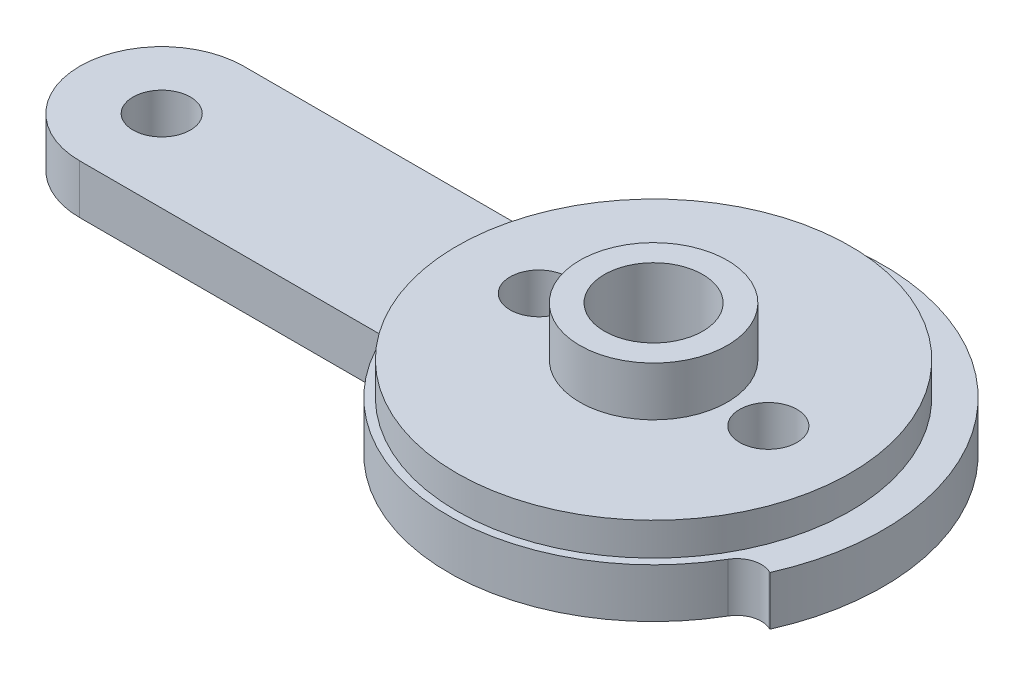
from build123d import *

# Parameters (mm, degrees)
SKETCH_1_R          = 1.75
EXTRUDE_1_DEPTH     = 3
SKETCH_2_R          = 12
EXTRUDE_2_DEPTH     = 2
SKETCH_3_R          = 4.5
SKETCH_3_R_2        = 3
EXTRUDE_3_DEPTH     = 3
SKETCH_4_R          = 3
CUT_EXTRUDE_1_DEPTH = 2
SKETCH_5_R          = 1.75
CUT_EXTRUDE_2_DEPTH = 9


with BuildPart() as part:
    # Эскиз1 → Бобышка-Вытянуть1 (new body)
    with BuildSketch(Plane(origin=(0, 0, 0), x_dir=(1, 0, 0), z_dir=(0, 1, 0))):
        with BuildLine():
            Line((-30, 5), (-11.456439237, 5))
            ThreePointArc((-11.456439237, 5), (-10.2750901, 7.118463559), (-8.706840344, 8.968886844))
            ThreePointArc((-8.706840344, 8.968886844), (-8.255178852, 9.942485712), (-8.569645055, 10.968645479))
            Line((-8.569645055, 10.968645479), (-8.619260655, 11.03215055))
            ThreePointArc((-8.619260655, 11.03215055), (8.619260655, 11.03215055), (12.789636407, -5.694313003))
            Line((12.789636407, -5.694313003), (12.716014607, -5.661534466))
            ThreePointArc((12.716014607, -5.661534466), (11.644259912, -5.604659769), (10.808847895, -6.278439868))
            ThreePointArc((10.808847895, -6.278439868), (-0.716551297, -12.47944527), (-11.456439237, -5))
            Line((-11.456439237, -5), (-30, -5))
            ThreePointArc((-30, -5), (-35, 0), (-30, 5))
        make_face()
        with Locations((-30, 0)):
            Circle(SKETCH_1_R, mode=Mode.SUBTRACT)
    extrude(amount=EXTRUDE_1_DEPTH)

    # Эскиз2 → Бобышка-Вытянуть2 (add)
    with BuildSketch(Plane(origin=(0, 3, 0), x_dir=(1, 0, 0), z_dir=(0, 1, 0))):
        Circle(SKETCH_2_R)
    extrude(amount=EXTRUDE_2_DEPTH)

    # Эскиз3 → Бобышка-Вытянуть3 (add)
    with BuildSketch(Plane(origin=(0, 5, 0), x_dir=(1, 0, 0), z_dir=(0, 1, 0))):
        Circle(SKETCH_3_R)
        Circle(SKETCH_3_R_2, mode=Mode.SUBTRACT)
    extrude(amount=EXTRUDE_3_DEPTH)

    # Эскиз4 → Вырез-Вытянуть1 (cut)
    with BuildSketch(Plane(origin=(0, 5, 0), x_dir=(1, 0, 0), z_dir=(0, 1, 0))):
        Circle(SKETCH_4_R)
    extrude(amount=-CUT_EXTRUDE_1_DEPTH, mode=Mode.SUBTRACT)

    # Эскиз5 → Вырез-Вытянуть2 (cut, through all)
    with BuildSketch(Plane(origin=(0, 8, 0), x_dir=(1, 0, 0), z_dir=(0, 1, 0))):
        Circle(SKETCH_5_R)
        with Locations((-7, 0)):
            Circle(SKETCH_5_R)
        with Locations((7, 0)):
            Circle(SKETCH_5_R)
    extrude(amount=-CUT_EXTRUDE_2_DEPTH, mode=Mode.SUBTRACT)


solid = part.part
